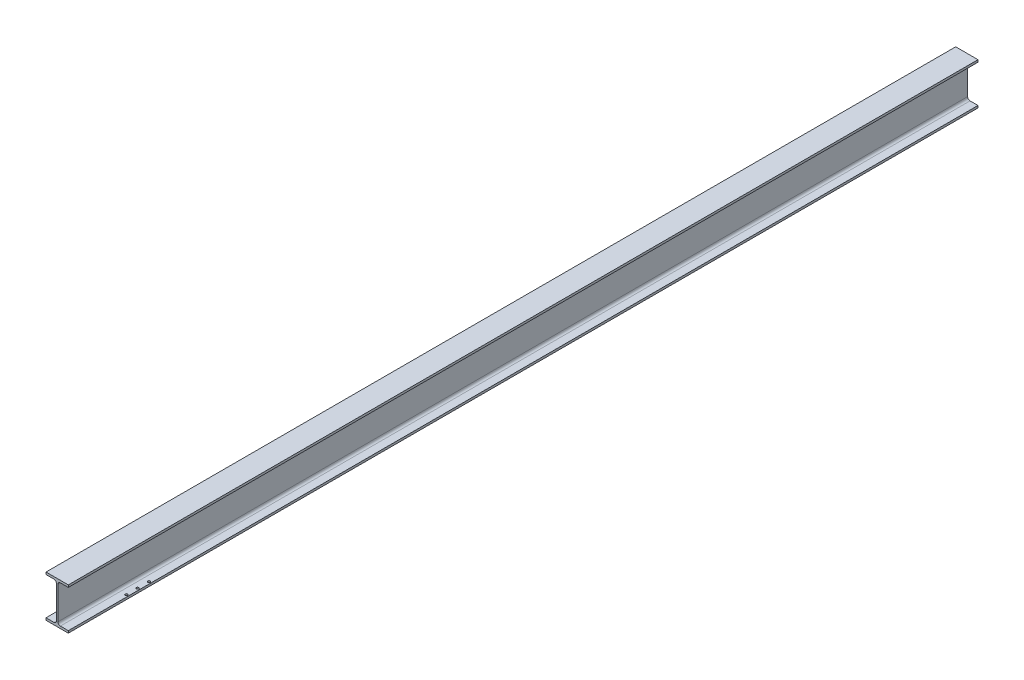
from build123d import *

# Parameters (mm, degrees)
BOSS_EXTRUDE1_DEPTH          = 1305
FILLET1_R                    = 7
F_7_0_7_DIAMETER_HOLE1_D     = 7
F_7_0_7_DIAMETER_HOLE1_DEPTH = 6.3
LPATTERN1_COUNT              = 3
LPATTERN1_PITCH              = 32.5
LPATTERN1_COUNT_DIR2         = 2
LPATTERN1_PITCH_DIR2         = 52


with BuildPart() as part:
    # Sketch1 → Boss-Extrude1 (new body, symmetric)
    with BuildSketch(Plane.XY):
        Polygon((0, 60), (0, -60), (-32, -60), (-32, -53.7), (-2.2, -53.7), (-2.2, 53.7), (-32, 53.7), (-32, 60), align=None)
    boss_extrude1 = extrude(amount=BOSS_EXTRUDE1_DEPTH, both=True)

    # Mirror1: Boss-Extrude1 across plane
    add(boss_extrude1.mirror(Plane(origin=(0, 60, 1305), x_dir=(0, 0, 1), z_dir=(-1, 0, 0))))

    # Fillet1
    fillet1_edges = [part.edges().sort_by_distance(p)[0] for p in [
        (-2.2, -53.7, 0),
        (-2.2, 53.7, 0),
        (2.2, -53.7, 0),
        (2.2, 53.7, 0),
    ]]
    fillet(fillet1_edges, radius=FILLET1_R)

    # Ø7.0 (7) Diameter Hole1
    with Locations(Plane(origin=(0, -60, 0), x_dir=(-1, 0, 0), z_dir=(0, -1, 0))):
        with Locations((-26, -1132.5)):
            f_7_0_7_diameter_hole1 = Hole(F_7_0_7_DIAMETER_HOLE1_D / 2, depth=F_7_0_7_DIAMETER_HOLE1_DEPTH)

    # LPattern1: 7.0 _7_ Diameter Hole1 3 × 2
    with Locations(*[(-j * LPATTERN1_PITCH_DIR2, 0, -i * LPATTERN1_PITCH) for i in range(LPATTERN1_COUNT) for j in range(LPATTERN1_COUNT_DIR2) if (i, j) != (0, 0)]):
        add(f_7_0_7_diameter_hole1, mode=Mode.SUBTRACT)


solid = part.part
